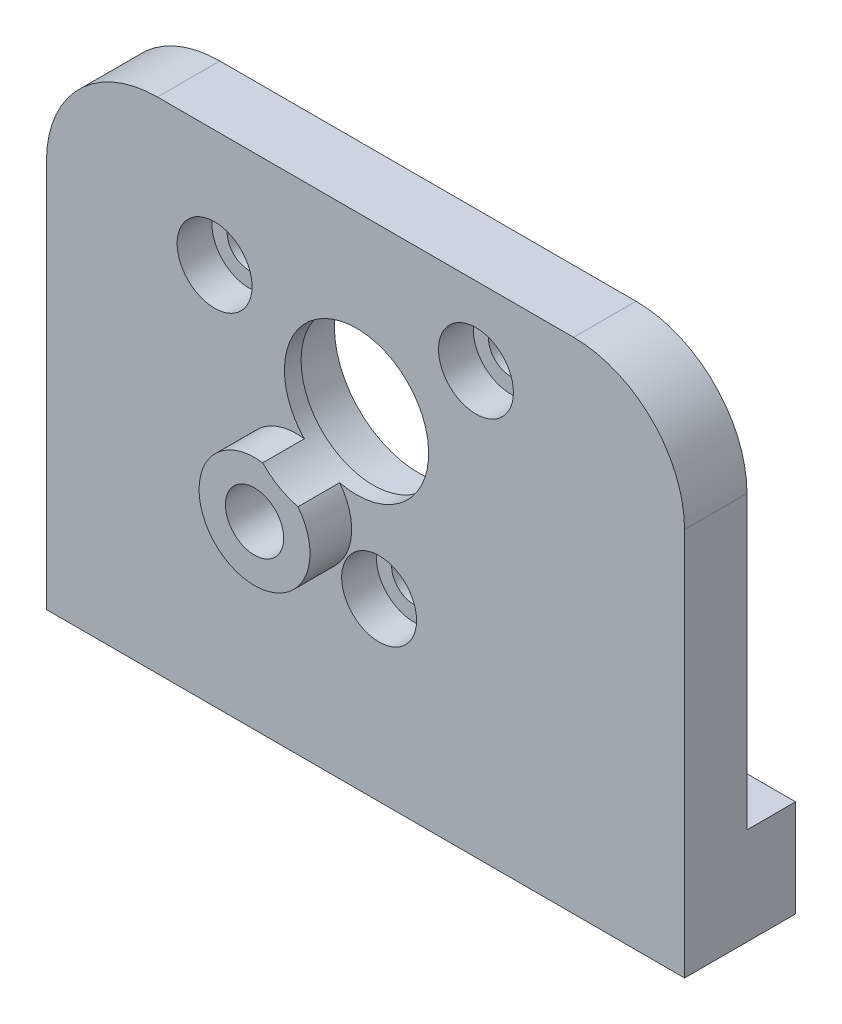
from build123d import *

# Parameters (mm, degrees)
SKETCH1_W                                        = 46
SKETCH1_H                                        = 36
BOSS_EXTRUDE1_DEPTH                              = 4.5
SKETCH2_W                                        = 8
SKETCH2_H                                        = 7
BOSS_EXTRUDE2_DEPTH                              = 3.5
SKETCH3_W                                        = 7.999999995
SKETCH3_H                                        = 7
BOSS_EXTRUDE3_DEPTH                              = 3.5
SKETCH4_W                                        = 4
SKETCH4_H                                        = 3
F_1_7_1_7_DIAMETER_HOLE1_D                       = 1.7
F_1_7_1_7_DIAMETER_HOLE1_DEPTH                   = 7
F_1_7_1_7_DIAMETER_HOLE1_TIP                     = 0.510731526
F_2_5_2_5_DIAMETER_HOLE1_D                       = 2.5
F_2_5_2_5_DIAMETER_HOLE1_DEPTH                   = 6
F_2_5_2_5_DIAMETER_HOLE1_TIP                     = 0.751075774
HOLE1_D                                          = 10.4
HOLE1_CBORE_D                                    = 12.2
HOLE1_CBORE_DEPTH                                = 3.3
CBORE_FOR_M3_HEX_HEAD_MACHINE_SCREW1_D           = 3.2
CBORE_FOR_M3_HEX_HEAD_MACHINE_SCREW1_DEPTH       = 8.000025
CBORE_FOR_M3_HEX_HEAD_MACHINE_SCREW1_CBORE_D     = 5.4
CBORE_FOR_M3_HEX_HEAD_MACHINE_SCREW1_CBORE_DEPTH = 2.5
F_4_2_4_2_DIAMETER_HOLE1_D                       = 4.2
F_4_2_4_2_DIAMETER_HOLE1_DEPTH                   = 7
FILLET1_R                                        = 3
FILLET2_R                                        = 8


with BuildPart() as part:
    # Sketch1 → Boss-Extrude1 (new body)
    with BuildSketch(Plane.XY.offset(4.5)):
        Rectangle(SKETCH1_W, SKETCH1_H)
    extrude(amount=-BOSS_EXTRUDE1_DEPTH)

    # Sketch2 → Boss-Extrude2 (add)
    with BuildSketch(Plane(origin=(0, 0, 0), x_dir=(-1, 0, 0), z_dir=(0, 0, -1))):
        with Locations((-19, -14.5)):
            Rectangle(SKETCH2_W, SKETCH2_H)
    extrude(amount=BOSS_EXTRUDE2_DEPTH)

    # Sketch3 → Boss-Extrude3 (add)
    with BuildSketch(Plane(origin=(0, 0, 0), x_dir=(-1, 0, 0), z_dir=(0, 0, -1))):
        with Locations((19.000000003, -14.5)):
            Rectangle(SKETCH3_W, SKETCH3_H)
    extrude(amount=BOSS_EXTRUDE3_DEPTH)

    # Sketch4 → Revolve1 (revolve)
    with BuildSketch(Plane.XZ.offset(2)):
        with Locations((-3, 6)):
            Rectangle(SKETCH4_W, SKETCH4_H)
    revolve(axis=Axis((-5, -2, 7.5), (0, 0, -1)))

    # Ø1.7 (1.7) Diameter Hole1
    with Locations(Plane(origin=(0, -18, 0), x_dir=(-1, 0, 0), z_dir=(0, -1, 0))):
        with Locations((0, -2.25)):
            Hole(F_1_7_1_7_DIAMETER_HOLE1_D / 2, depth=F_1_7_1_7_DIAMETER_HOLE1_DEPTH)
            with Locations((0, 0, -(F_1_7_1_7_DIAMETER_HOLE1_DEPTH + F_1_7_1_7_DIAMETER_HOLE1_TIP / 2))):  # 118° drill point
                Cone(0, F_1_7_1_7_DIAMETER_HOLE1_D / 2, F_1_7_1_7_DIAMETER_HOLE1_TIP, mode=Mode.SUBTRACT)

    # Ø2.5 (2.5) Diameter Hole1
    with Locations(Plane(origin=(0, -18, 0), x_dir=(-1, 0, 0), z_dir=(0, -1, 0))):
        with Locations((-19, -0.5), (19, -0.5)):
            Hole(F_2_5_2_5_DIAMETER_HOLE1_D / 2, depth=F_2_5_2_5_DIAMETER_HOLE1_DEPTH)
            with Locations((0, 0, -(F_2_5_2_5_DIAMETER_HOLE1_DEPTH + F_2_5_2_5_DIAMETER_HOLE1_TIP / 2))):  # 118° drill point
                Cone(0, F_2_5_2_5_DIAMETER_HOLE1_D / 2, F_2_5_2_5_DIAMETER_HOLE1_TIP, mode=Mode.SUBTRACT)

    # Hole1 (through all)
    with Locations(Plane(origin=(0, 0, 0), x_dir=(-1, 0, 0), z_dir=(0, 0, -1))):
        with Locations((0.645780782, 5.541728913)):
            CounterBoreHole(HOLE1_D / 2, HOLE1_CBORE_D / 2, HOLE1_CBORE_DEPTH)

    # CBORE for M3 Hex Head Machine Screw1
    with Locations(Plane.XY.offset(4.5)):
        with Locations((0.980122741, -5.337445584), (7.962908944, 12.389389916), (-10.88037403, 9.573242407)):
            CounterBoreHole(CBORE_FOR_M3_HEX_HEAD_MACHINE_SCREW1_D / 2, CBORE_FOR_M3_HEX_HEAD_MACHINE_SCREW1_CBORE_D / 2, CBORE_FOR_M3_HEX_HEAD_MACHINE_SCREW1_CBORE_DEPTH, depth=CBORE_FOR_M3_HEX_HEAD_MACHINE_SCREW1_DEPTH)

    # Ø4.2 (4.2) Diameter Hole1
    with Locations(Plane.XY.offset(7.5)):
        with Locations((-5, -2)):
            Hole(F_4_2_4_2_DIAMETER_HOLE1_D / 2, depth=F_4_2_4_2_DIAMETER_HOLE1_DEPTH)

    # Fillet1
    fillet1_edges = [part.edges().sort_by_distance(p)[0] for p in [
        (-15.000000005, -11, -1.75),
        (15, -11, -1.75),
    ]]
    fillet(fillet1_edges, radius=FILLET1_R)

    # Fillet2
    fillet2_edges = [part.edges().sort_by_distance(p)[0] for p in [
        (-23, 18, 2.25),
        (23, 18, 2.25),
    ]]
    fillet(fillet2_edges, radius=FILLET2_R)


solid = part.part
